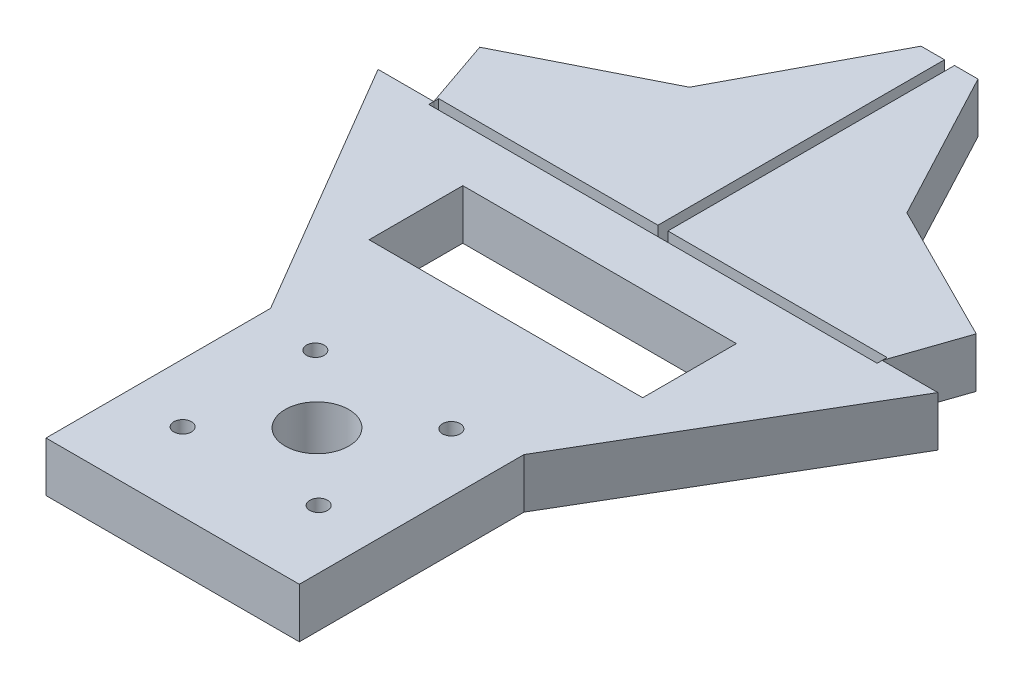
from build123d import *

# Parameters (mm, degrees)
BOSS_EXTRUDE1_DEPTH = 10
CUT_EXTRUDE1_DEPTH  = 10
SKETCH3_R           = 1.78
SKETCH3_R_2         = 6.3754
CUT_EXTRUDE2_DEPTH  = 10
SKETCH4_W           = 54.864
SKETCH4_H           = 18.796
CUT_EXTRUDE3_DEPTH  = 10


with BuildPart() as part:
    # Sketch1 → Boss-Extrude1 (new body)
    with BuildSketch(Plane(origin=(0, 0, 0), x_dir=(1, 0, 0), z_dir=(0, 1, 0))):
        Polygon((21.809458386, -30.355701196), (5.70896, 0), (0, 0), (0, -58.4708), (44.953527672, -58.4708), (49.778195113, -44.423058366), align=None)
        Polygon((0, -58.4708), (0, 0), (-5.70896, 0), (-21.809458386, -30.355701196), (-49.778195113, -44.423058366), (-44.953527672, -58.4708), align=None)
        Polygon((44.953527672, -58.4708), (0, -58.4708), (-44.953527672, -58.4708), (-56.122917264, -58.4708), (-25.4, -110.742004672), (-25.4, -155.77676904), (25.4, -155.77676904), (25.4, -110.742004672), (56.122917264, -58.4708), align=None)
    extrude(amount=BOSS_EXTRUDE1_DEPTH)

    # Sketch2 → Cut-Extrude1 (cut)
    with BuildSketch(Plane(origin=(0, 10, 0), x_dir=(1, 0, 0), z_dir=(0, 1, 0))):
        Polygon((-1, 0), (-1, -57.4708), (-44.953527672, -57.4708), (-44.953527672, -59.4708), (44.953527672, -59.4708), (44.953527672, -57.4708), (1, -57.4708), (1, 0), align=None)
    extrude(amount=-CUT_EXTRUDE1_DEPTH, mode=Mode.SUBTRACT)

    # Sketch3 → Cut-Extrude2 (cut)
    with BuildSketch(Plane(origin=(0, 10, 0), x_dir=(1, 0, 0), z_dir=(0, 1, 0))):
        with Locations((-13.638317973, -140.137106355)):
            Circle(SKETCH3_R)
        with Locations((13.638317973, -140.137106355)):
            Circle(SKETCH3_R)
        with Locations((13.638317973, -113.536445998)):
            Circle(SKETCH3_R)
        with Locations((-13.638317973, -113.536445998)):
            Circle(SKETCH3_R)
        with Locations((0, -126.836776177)):
            Circle(SKETCH3_R_2)
    extrude(amount=-CUT_EXTRUDE2_DEPTH, mode=Mode.SUBTRACT)

    # Sketch4 → Cut-Extrude3 (cut)
    with BuildSketch(Plane(origin=(0, 10, 0), x_dir=(1, 0, 0), z_dir=(0, 1, 0))):
        with Locations((0, -79.563322367)):
            Rectangle(SKETCH4_W, SKETCH4_H)
    extrude(amount=-CUT_EXTRUDE3_DEPTH, mode=Mode.SUBTRACT)


solid = part.part
